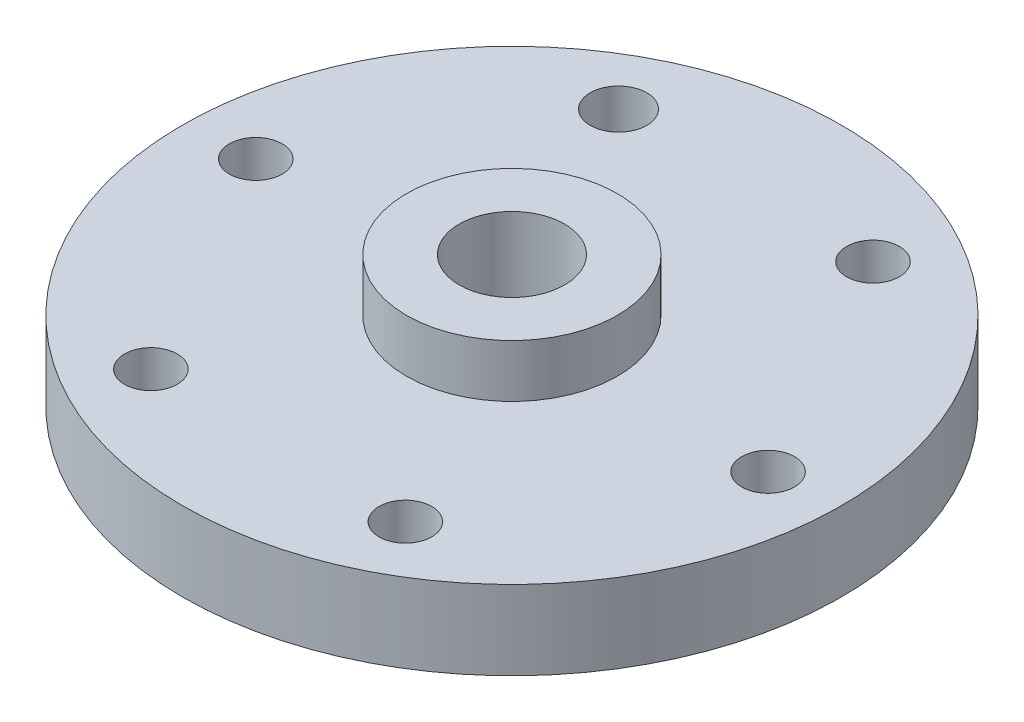
from build123d import *

# Parameters (mm, degrees)
SKETCH1_R           = 12.5
BOSS_EXTRUDE1_DEPTH = 3
SKETCH2_R           = 4
BOSS_EXTRUDE2_DEPTH = 5
SKETCH5_R           = 2
CUT_EXTRUDE3_DEPTH  = 8
SKETCH4_R           = 1
CUT_EXTRUDE4_DEPTH  = 8
SKETCH3_R           = 1
CUT_EXTRUDE7_DEPTH  = 3
SKETCH11_R          = 1.073090014
SKETCH11_R_2        = 1
CUT_EXTRUDE9_DEPTH  = 3


with BuildPart() as part:
    # Sketch1 → Boss-Extrude1 (new body)
    with BuildSketch(Plane(origin=(0, 0, 0), x_dir=(1, 0, 0), z_dir=(0, 1, 0))):
        Circle(SKETCH1_R)
    extrude(amount=BOSS_EXTRUDE1_DEPTH)

    # Sketch2 → Boss-Extrude2 (add)
    with BuildSketch(Plane(origin=(0, 0, 0), x_dir=(1, 0, 0), z_dir=(0, 1, 0))):
        Circle(SKETCH2_R)
    extrude(amount=BOSS_EXTRUDE2_DEPTH)

    # Sketch5 → Cut-Extrude3 (cut)
    with BuildSketch(Plane(origin=(0, 5, 0), x_dir=(1, 0, 0), z_dir=(0, 1, 0))):
        Circle(SKETCH5_R)
    extrude(amount=-CUT_EXTRUDE3_DEPTH, mode=Mode.SUBTRACT)

    # Sketch4 → Cut-Extrude4 (cut)
    with BuildSketch(Plane(origin=(0, 3, 0), x_dir=(1, 0, 0), z_dir=(0, 1, 0))):
        with Locations((5.080770429, 8.613345791)):
            Circle(SKETCH4_R)
    extrude(amount=-CUT_EXTRUDE4_DEPTH, mode=Mode.SUBTRACT)

    # Sketch3 → Cut-Extrude7 (cut)
    with BuildSketch(Plane(origin=(0, 0, 0), x_dir=(1, 0, 0), z_dir=(0, 1, 0))):
        with Locations((-5.080770429, -8.613345791)):
            Circle(SKETCH3_R)
    extrude(amount=CUT_EXTRUDE7_DEPTH, mode=Mode.SUBTRACT)

    # Sketch11 → Cut-Extrude9 (cut)
    with BuildSketch(Plane(origin=(0, 3, 0), x_dir=(1, 0, 0), z_dir=(0, 1, 0))):
        with Locations((-4.754881291, 8.797221374)):
            Circle(SKETCH11_R)
        with Locations((-9.996057838, 0.280762697)):
            Circle(SKETCH11_R_2)
        with Locations((4.754881291, -8.797221374)):
            Circle(SKETCH11_R_2)
        with Locations((9.996057838, -0.280762697)):
            Circle(SKETCH11_R_2)
    extrude(amount=-CUT_EXTRUDE9_DEPTH, mode=Mode.SUBTRACT)


solid = part.part
